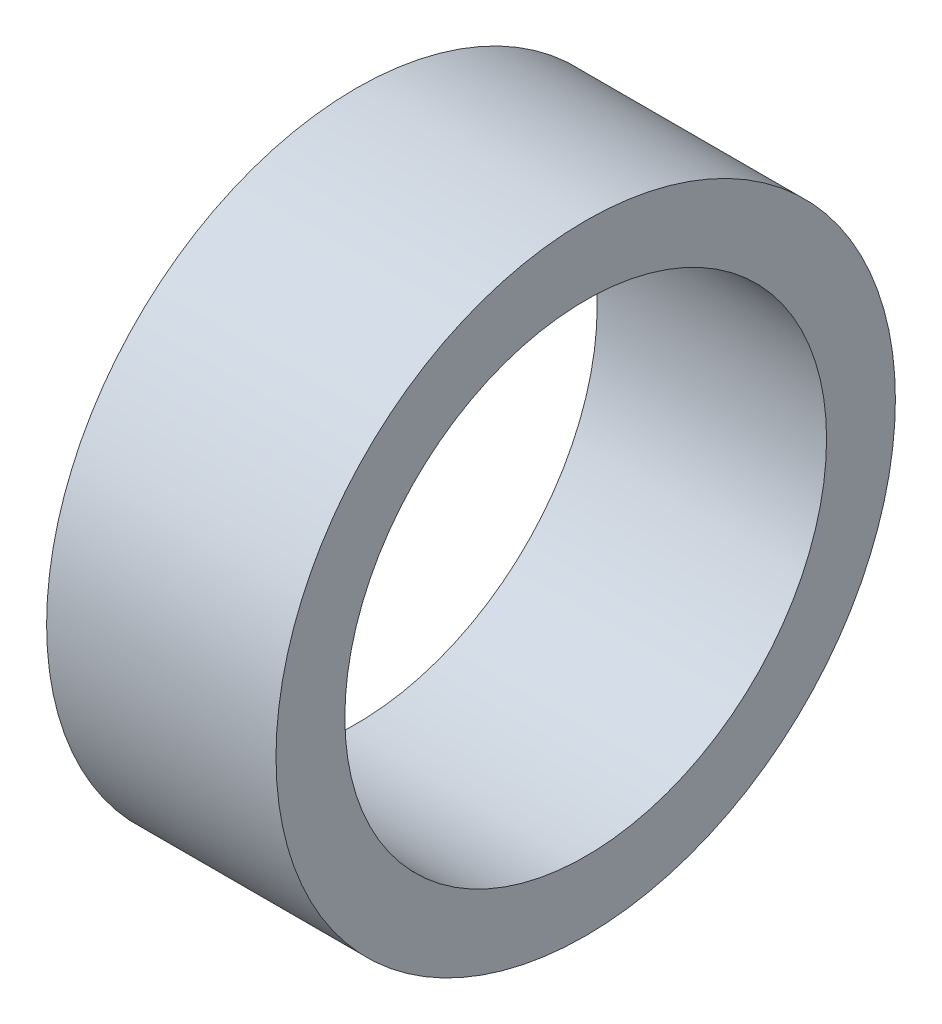
from build123d import *

# Parameters (mm, degrees)
SKETCH_1_R      = 6.75
SKETCH_1_R_2    = 5.25
EXTRUDE_1_DEPTH = 5


with BuildPart() as part:
    # Эскиз1 → Бобышка-Вытянуть1 (new body)
    with BuildSketch(Plane(origin=(0, 0, 0), x_dir=(0, 0, -1), z_dir=(1, 0, 0))):
        Circle(SKETCH_1_R)
        Circle(SKETCH_1_R_2, mode=Mode.SUBTRACT)
    extrude(amount=EXTRUDE_1_DEPTH)


solid = part.part
